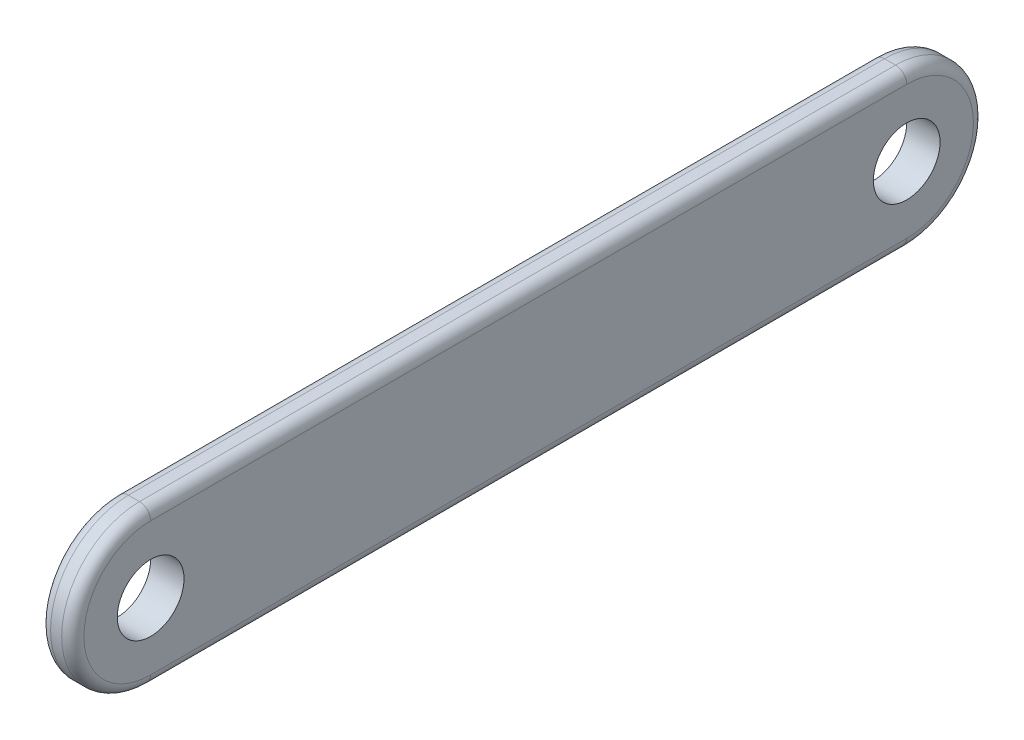
from build123d import *

# Parameters (mm, degrees)
SKETCH_1_R      = 3
EXTRUDE_1_DEPTH = 3
FILLET_1_R      = 1


with BuildPart() as part:
    # 草图1 → 凸台-拉伸1 (new body)
    with BuildSketch(Plane(origin=(0, 0, 0), x_dir=(0, 0, -1), z_dir=(1, 0, 0))):
        with BuildLine():
            Line((-34, 7), (34, 7))
            ThreePointArc((34, 7), (41, 0), (34, -7))
            Line((34, -7), (-34, -7))
            ThreePointArc((-34, -7), (-41, 0), (-34, 7))
        make_face()
        with Locations((-34, 0)):
            Circle(SKETCH_1_R, mode=Mode.SUBTRACT)
        with Locations((34, 0)):
            Circle(SKETCH_1_R, mode=Mode.SUBTRACT)
    extrude(amount=EXTRUDE_1_DEPTH)

    # 圆角1
    fillet_1_edges = [part.edges().sort_by_distance(p)[0] for p in [
        (3, 0, -41),
        (3, 7, 0),
        (3, 0, 41),
        (0, 7, 0),
        (0, 0, -41),
        (0, -7, 0),
        (0, 0, 41),
        (3, -7, 0),
    ]]
    fillet(fillet_1_edges, radius=FILLET_1_R)


solid = part.part
